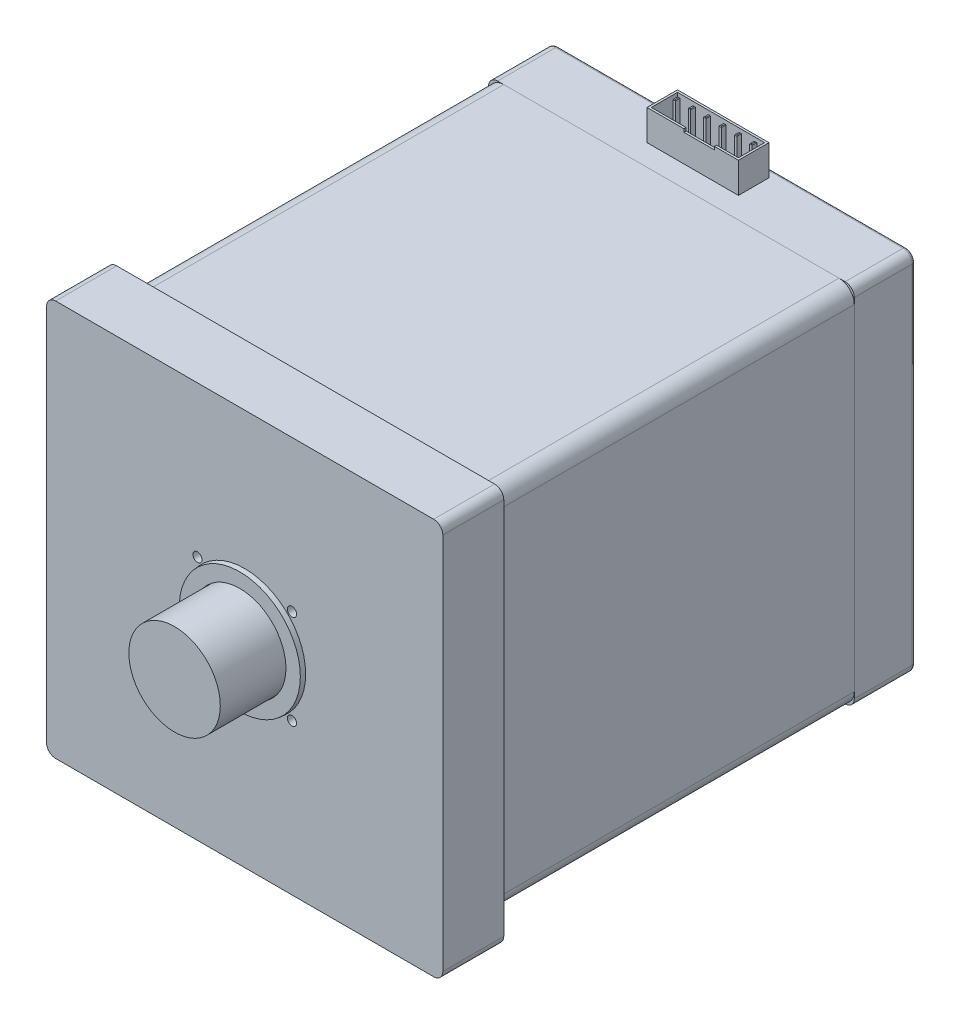
from build123d import *

# Parameters (mm, degrees)
SKETCH_1_R          = 1.5
EXTRUDE_1_DEPTH     = 20
SKETCH_4_R          = 15
EXTRUDE_2_DEPTH     = 23
SKETCH_9_W          = 120
SKETCH_9_H          = 120
EXTRUDE_7_DEPTH     = 120
SKETCH_10_W         = 120
SKETCH_10_H         = 120
EXTRUDE_8_DEPTH     = 20
FILLET_1_R          = 3
FILLET_2_R          = 5
SKETCH_12_R         = 1.5
SKETCH_12_R_2       = 1.518540069
CUT_EXTRUDE_1_DEPTH = 161
SKETCH_14_W         = 30
SKETCH_14_H         = 10
SKETCH_14_W_2       = 28.6
SKETCH_14_H_2       = 8.6
SKETCH_14_W_3       = 0.8
SKETCH_14_H_3       = 1.5
EXTRUDE_10_DEPTH    = 10
CHAMFER_1_SIZE      = 0.2
SKETCH_15_W         = 10
SKETCH_15_H         = 1
CUT_EXTRUDE_2_DEPTH = 0.7
FILLET_3_R          = 1
SKETCH_16_R         = 20
SKETCH_16_R_2       = 15
EXTRUDE_11_DEPTH    = 1.6
EXTRUDE_11_TAPER    = 5


with BuildPart() as part:
    # 草图1 → 凸台-拉伸1 (new body)
    with BuildSketch(Plane.XY):
        with BuildLine():
            Line((-62, 65), (62, 65))
            ThreePointArc((62, 65), (64.121320344, 64.121320344), (65, 62))
            Line((65, 62), (65, -62))
            ThreePointArc((65, -62), (64.121320344, -64.121320344), (62, -65))
            Line((62, -65), (-62, -65))
            ThreePointArc((-62, -65), (-64.121320344, -64.121320344), (-65, -62))
            Line((-65, -62), (-65, 62))
            ThreePointArc((-65, 62), (-64.121320344, 64.121320344), (-62, 65))
        make_face()
        with Locations((-15.5, 15.5)):
            Circle(SKETCH_1_R, mode=Mode.SUBTRACT)
        with Locations((15.5, 15.5)):
            Circle(SKETCH_1_R, mode=Mode.SUBTRACT)
        with Locations((15.5, -15.5)):
            Circle(SKETCH_1_R, mode=Mode.SUBTRACT)
        with Locations((-15.5, -15.5)):
            Circle(SKETCH_1_R, mode=Mode.SUBTRACT)
    extrude(amount=EXTRUDE_1_DEPTH)

    # 草图4 → 凸台-拉伸2 (add)
    with BuildSketch(Plane.XY.offset(20)):
        Circle(SKETCH_4_R)
    extrude(amount=EXTRUDE_2_DEPTH)


with BuildPart() as body_2:
    # 草图9 → 凸台-拉伸7 (new body)
    with BuildSketch(Plane(origin=(0, 0, 0), x_dir=(-1, 0, 0), z_dir=(0, 0, -1))):
        Rectangle(SKETCH_9_W, SKETCH_9_H)
    extrude(amount=EXTRUDE_7_DEPTH)

    # 圆角2
    fillet_2_edges = [body_2.edges().sort_by_distance(p)[0] for p in [
        (-60, -60, -60),
        (60, -60, -60),
        (60, 60, -60),
        (-60, 60, -60),
    ]]
    fillet(fillet_2_edges, radius=FILLET_2_R)


with BuildPart() as body_3:
    # 草图10 → 凸台-拉伸8 (new body)
    with BuildSketch(Plane(origin=(0, 0, -120), x_dir=(-1, 0, 0), z_dir=(0, 0, -1))):
        Rectangle(SKETCH_10_W, SKETCH_10_H)
    extrude(amount=EXTRUDE_8_DEPTH)

    # 圆角1
    fillet_1_edges = [body_3.edges().sort_by_distance(p)[0] for p in [
        (60, 60, -130),
        (-60, 60, -130),
        (-60, -60, -130),
        (60, -60, -130),
    ]]
    fillet(fillet_1_edges, radius=FILLET_1_R)


with BuildPart() as cut_extrude_1_tool:
    # 草图12 → 切除-拉伸1 (new body, through all)
    with BuildSketch(Plane.XY.offset(20)):
        with Locations((-15.5, 15.5)):
            Circle(SKETCH_12_R)
        with Locations((15.518540069, 15.5)):
            Circle(SKETCH_12_R_2)
        with Locations((-15.5, -15.5)):
            Circle(SKETCH_12_R)
        with Locations((15.5, -15.5)):
            Circle(SKETCH_12_R)
    extrude(amount=-CUT_EXTRUDE_1_DEPTH)


with BuildPart() as part_1:
    add(part.part)

    # 切除-拉伸1: cut by cut_extrude_1_tool
    add(cut_extrude_1_tool.part, mode=Mode.SUBTRACT)

    # 草图16 → 凸台-拉伸11 (add)
    with BuildSketch(Plane.XY.offset(20)):
        Circle(SKETCH_16_R)
        Circle(SKETCH_16_R_2, mode=Mode.SUBTRACT)
    extrude(amount=EXTRUDE_11_DEPTH, taper=EXTRUDE_11_TAPER)


with BuildPart() as body_2_1:
    add(body_2.part)

    # 切除-拉伸1: cut by cut_extrude_1_tool
    add(cut_extrude_1_tool.part, mode=Mode.SUBTRACT)


with BuildPart() as body_3_1:
    add(body_3.part)

    # 切除-拉伸1: cut by cut_extrude_1_tool
    add(cut_extrude_1_tool.part, mode=Mode.SUBTRACT)

    # 草图14 → 凸台-拉伸10 (add)
    with BuildSketch(Plane(origin=(0, 60, 0), x_dir=(1, 0, 0), z_dir=(0, 1, 0))):
        with Locations((0, 132)):
            Rectangle(SKETCH_14_W, SKETCH_14_H)
        with Locations((0, 132)):
            Rectangle(SKETCH_14_W_2, SKETCH_14_H_2, mode=Mode.SUBTRACT)
        with Locations((-12.8, 134.457329348)):
            Rectangle(SKETCH_14_W_3, SKETCH_14_H_3)
        with Locations((-2.72, 134.457329348)):
            Rectangle(SKETCH_14_W_3, SKETCH_14_H_3)
        with Locations((12.4, 134.457329348)):
            Rectangle(SKETCH_14_W_3, SKETCH_14_H_3)
        with Locations((7.36, 134.457329348)):
            Rectangle(SKETCH_14_W_3, SKETCH_14_H_3)
        with Locations((-7.76, 134.457329348)):
            Rectangle(SKETCH_14_W_3, SKETCH_14_H_3)
        with Locations((2.32, 134.457329348)):
            Rectangle(SKETCH_14_W_3, SKETCH_14_H_3)
    extrude(amount=EXTRUDE_10_DEPTH)

    # 倒角1
    chamfer_1_edges = [body_3_1.edges().sort_by_distance(p)[0] for p in [
        (12.8, 70, -134.457329348),
        (12.4, 70, -135.207329348),
        (12, 70, -134.457329348),
        (12.4, 70, -133.707329348),
        (7.76, 70, -134.457329348),
        (7.36, 70, -135.207329348),
        (6.96, 70, -134.457329348),
        (7.36, 70, -133.707329348),
        (-7.36, 70, -134.457329348),
        (-7.76, 70, -135.207329348),
        (-8.16, 70, -134.457329348),
        (-7.76, 70, -133.707329348),
        (2.72, 70, -134.457329348),
        (2.32, 70, -135.207329348),
        (1.92, 70, -134.457329348),
        (2.32, 70, -133.707329348),
        (-12.4, 70, -134.457329348),
        (-12.8, 70, -135.207329348),
        (-13.2, 70, -134.457329348),
        (-12.8, 70, -133.707329348),
        (-2.32, 70, -134.457329348),
        (-2.72, 70, -135.207329348),
        (-3.12, 70, -134.457329348),
        (-2.72, 70, -133.707329348),
    ]]
    chamfer(chamfer_1_edges, length=CHAMFER_1_SIZE)

    # 草图15 → 切除-拉伸2 (cut)
    with BuildSketch(Plane.XY.offset(-127)):
        with Locations((2.12, 69.5)):
            Rectangle(SKETCH_15_W, SKETCH_15_H)
    extrude(amount=-CUT_EXTRUDE_2_DEPTH, mode=Mode.SUBTRACT)

    # 圆角3
    fillet_3_edges = [body_3_1.edges().sort_by_distance(p)[0] for p in [
        (0, -60, -140),
        (60, 0, -140),
        (-60, 0, -140),
        (0, 60, -140),
        (59.121320344, 59.121320344, -140),
        (-59.121320344, 59.121320344, -140),
        (-59.121320344, -59.121320344, -140),
        (59.121320344, -59.121320344, -140),
    ]]
    fillet(fillet_3_edges, radius=FILLET_3_R)


solid = Compound([part_1.part, body_2_1.part, body_3_1.part])
